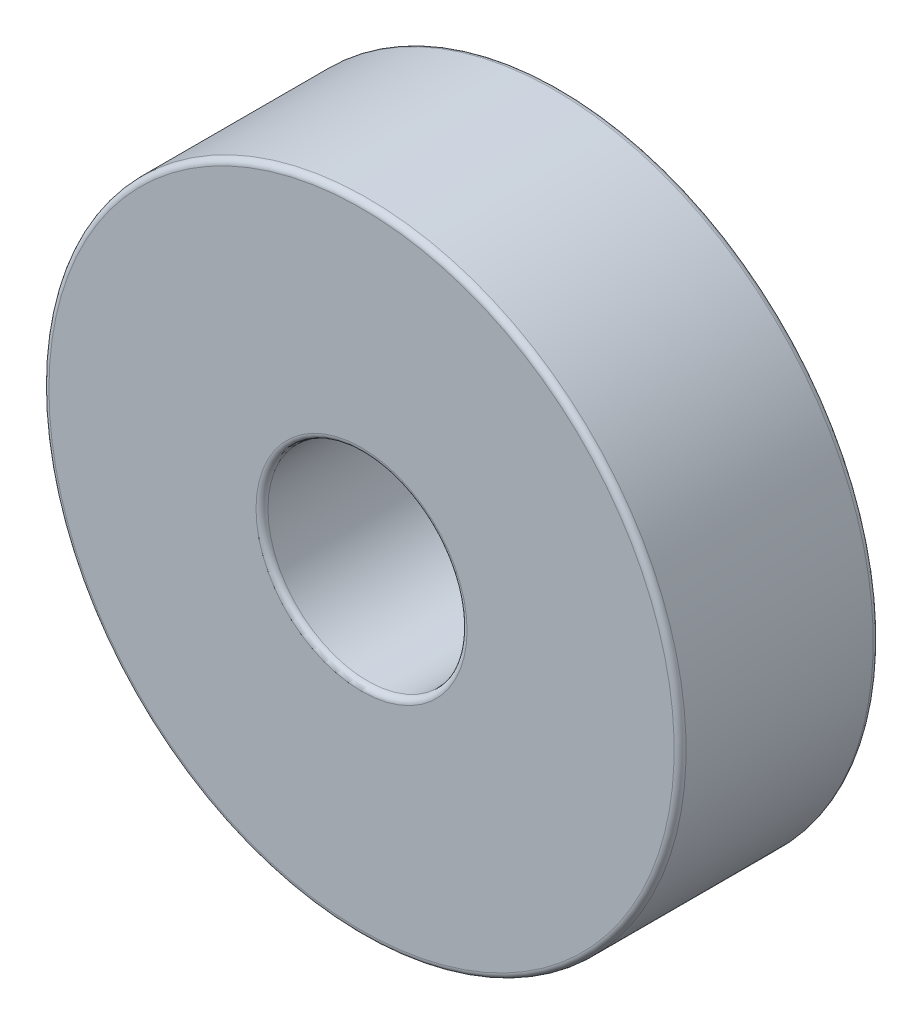
from build123d import *


with BuildPart() as part:
    # Sketch1 → Revolve1 (revolve)
    with BuildSketch(Plane(origin=(0, 0, 0), x_dir=(0, 0, -1), z_dir=(1, 0, 0))):
        with BuildLine():
            Line((5, 2.65), (5, 7.85))
            ThreePointArc((5, 7.85), (4.956066017, 7.956066017), (4.85, 8))
            Line((4.85, 8), (0.15, 8))
            ThreePointArc((0.15, 8), (0.043933983, 7.956066017), (0, 7.85))
            Line((0, 7.85), (0, 2.65))
            ThreePointArc((0, 2.65), (0.043933983, 2.543933983), (0.15, 2.5))
            Line((0.15, 2.5), (4.85, 2.5))
            ThreePointArc((4.85, 2.5), (4.956066017, 2.543933983), (5, 2.65))
        make_face()
    revolve(axis=Axis((0, 0, 0), (0, 0, 1)))


solid = part.part
